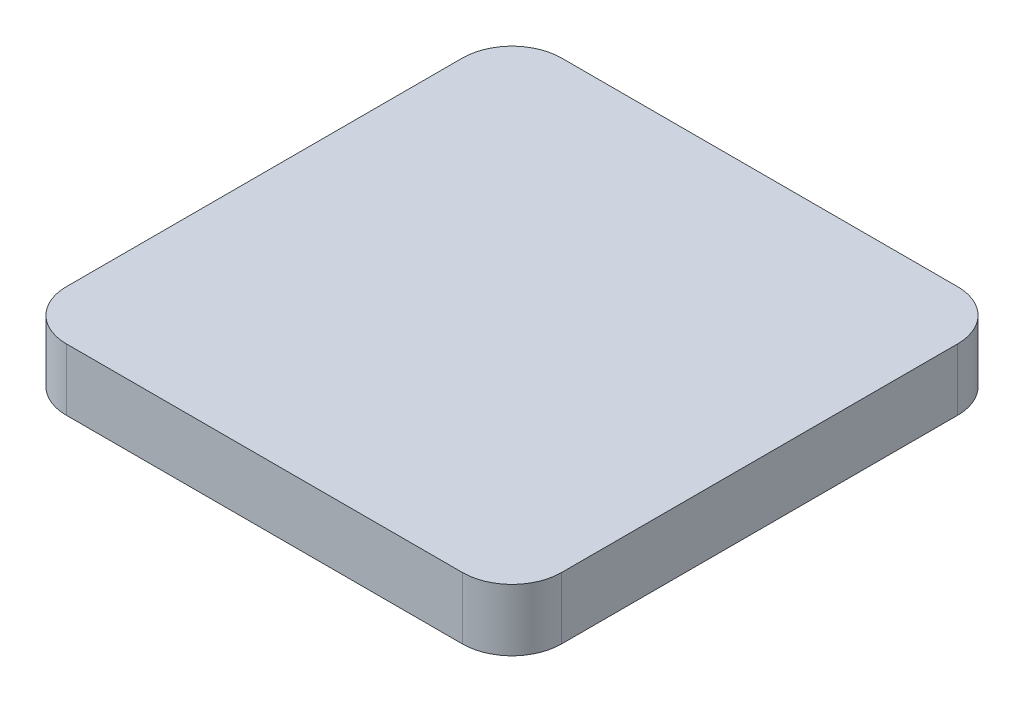
from build123d import *

# Parameters (mm, degrees)
SKETCH1_W           = 25.4
SKETCH1_H           = 25.4
BOSS_EXTRUDE1_DEPTH = 3.175
FILLET1_R           = 2.54


with BuildPart() as part:
    # Sketch1 → Boss-Extrude1 (new body)
    with BuildSketch(Plane(origin=(0, 0, 0), x_dir=(1, 0, 0), z_dir=(0, 1, 0))):
        Rectangle(SKETCH1_W, SKETCH1_H)
    extrude(amount=BOSS_EXTRUDE1_DEPTH)

    # Fillet1
    fillet1_edges = [part.edges().sort_by_distance(p)[0] for p in [
        (12.7, 1.5875, 12.7),
        (-12.7, 1.5875, 12.7),
        (-12.7, 1.5875, -12.7),
        (12.7, 1.5875, -12.7),
    ]]
    fillet(fillet1_edges, radius=FILLET1_R)


solid = part.part
